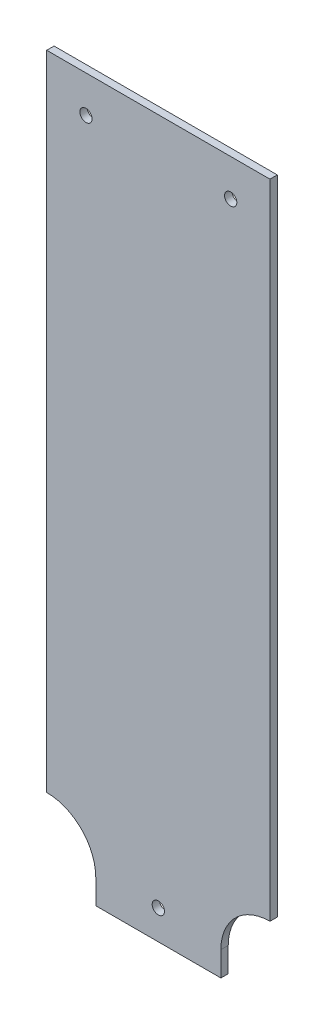
from build123d import *

# Parameters (mm, degrees)
ESQUISSE1_R      = 2.5
EXTRUSION1_DEPTH = 3


with BuildPart() as part:
    # Esquisse1 → Extrusion1 (new body)
    with BuildSketch(Plane.XY):
        with BuildLine():
            Line((45.5, 292), (-45.5, 292))
            Line((-45.5, 292), (-45.5, 30))
            ThreePointArc((-45.5, 30), (-31.357864376, 24.142135624), (-25.5, 10))
            Line((-25.5, 10), (-25.5, 0))
            Line((-25.5, 0), (25.5, 0))
            Line((25.5, 0), (25.5, 10))
            ThreePointArc((25.5, 10), (31.357864376, 24.142135624), (45.5, 30))
            Line((45.5, 30), (45.5, 292))
        make_face()
        with Locations((-29.5, 277)):
            Circle(ESQUISSE1_R, mode=Mode.SUBTRACT)
        with Locations((29.5, 277)):
            Circle(ESQUISSE1_R, mode=Mode.SUBTRACT)
        with Locations((0, 12)):
            Circle(ESQUISSE1_R, mode=Mode.SUBTRACT)
    extrude(amount=EXTRUSION1_DEPTH)


solid = part.part
